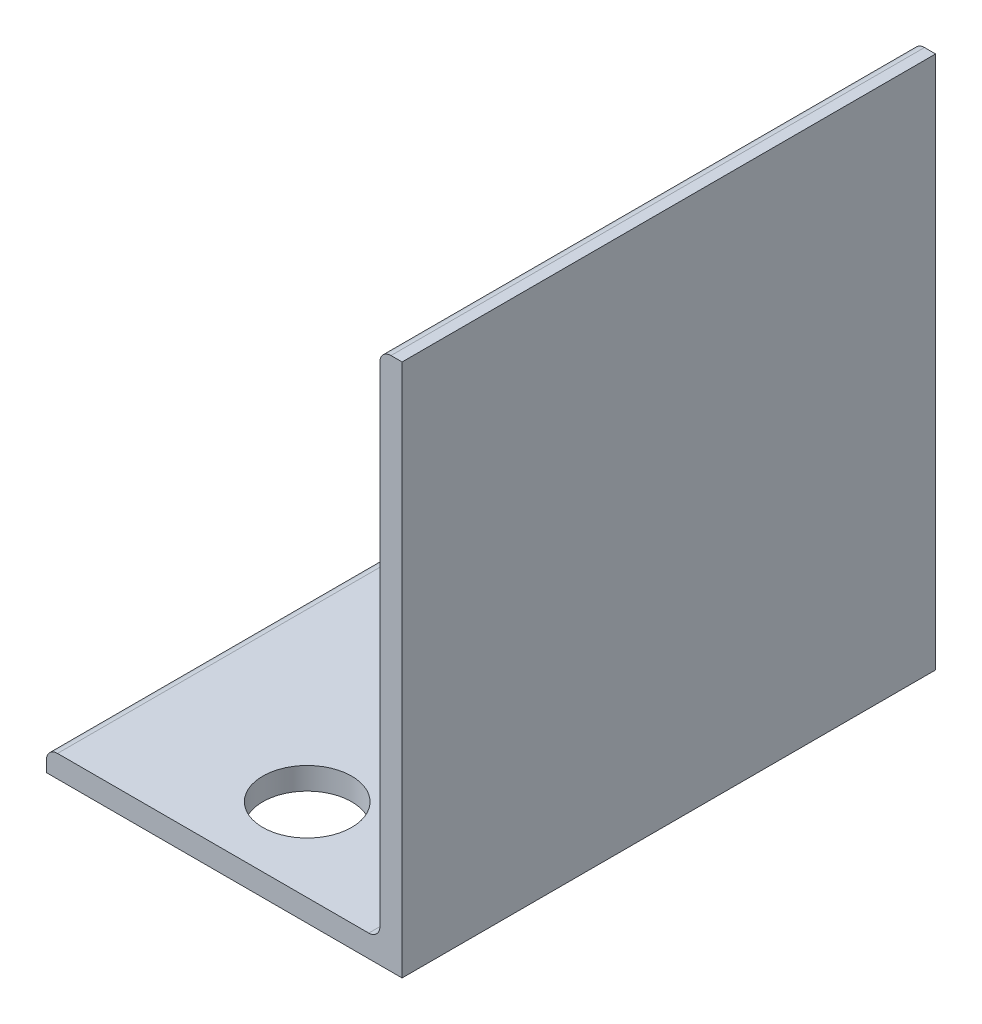
from build123d import *

# Parameters (mm, degrees)
BOSS_EXTRUDE1_DEPTH = 76.2
SKETCH3_R           = 12.7
SKETCH3_R_2         = 10
CUT_EXTRUDE1_DEPTH  = 7.35


with BuildPart() as part:
    # Sketch2 → Boss-Extrude1 (new body, symmetric)
    with BuildSketch(Plane.XY):
        with BuildLine():
            Line((-50.8, 0), (50.8, 0))
            Line((50.8, 0), (50.8, 152.4))
            Line((50.8, 152.4), (47.625, 152.4))
            ThreePointArc((47.625, 152.4), (45.37993597, 151.47006403), (44.45, 149.225))
            Line((44.45, 149.225), (44.45, 9.525))
            ThreePointArc((44.45, 9.525), (43.52006403, 7.27993597), (41.275, 6.35))
            Line((41.275, 6.35), (-47.625, 6.35))
            ThreePointArc((-47.625, 6.35), (-49.87006403, 5.42006403), (-50.8, 3.175))
            Line((-50.8, 3.175), (-50.8, 0))
        make_face()
    extrude(amount=BOSS_EXTRUDE1_DEPTH, both=True)

    # Sketch3 → Cut-Extrude1 (cut, through all)
    with BuildSketch(Plane(origin=(0, 6.35, 0), x_dir=(1, 0, 0), z_dir=(0, 1, 0))):
        with Locations((0, 52.5)):
            Circle(SKETCH3_R)
        with Locations((0, -52.5)):
            Circle(SKETCH3_R)
        Circle(SKETCH3_R_2)
    extrude(amount=-CUT_EXTRUDE1_DEPTH, mode=Mode.SUBTRACT)


solid = part.part
